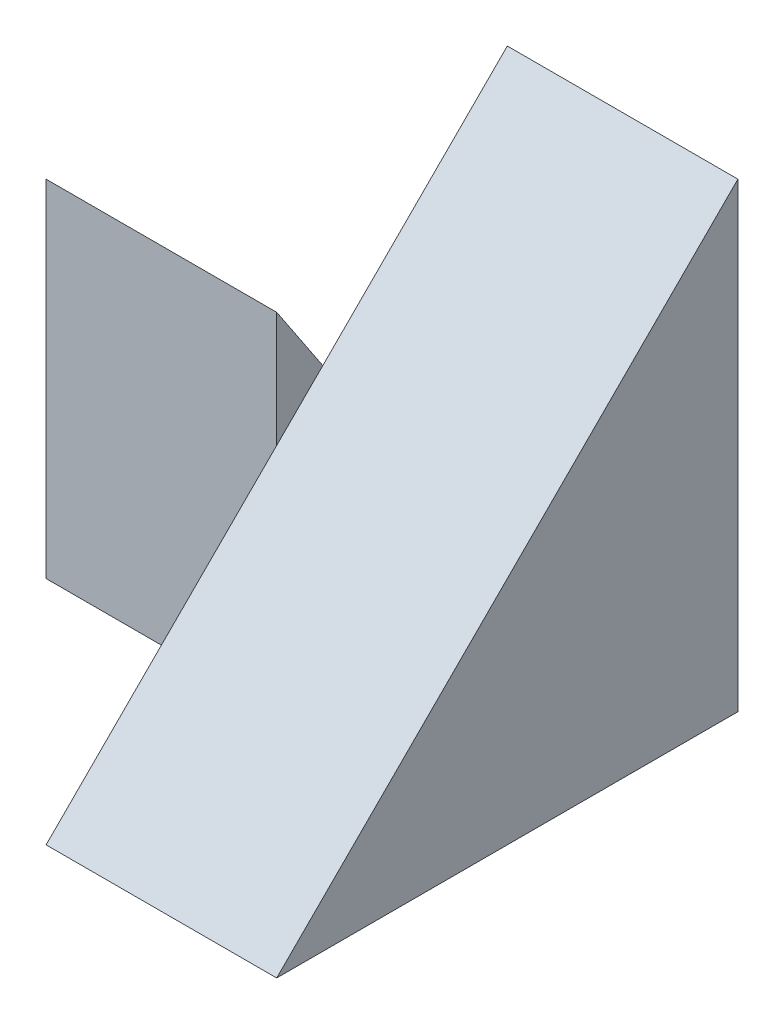
from build123d import *

# Parameters (mm, degrees)
SKETCH1_W           = 4
SKETCH1_H           = 4
BOSS_EXTRUDE1_DEPTH = 2
SKETCH2_W           = 2
SKETCH2_H           = 3
BOSS_EXTRUDE2_DEPTH = 2
CUT_EXTRUDE1_DEPTH  = 2
CUT_EXTRUDE2_DEPTH  = 2


with BuildPart() as part:
    # Sketch1 → Boss-Extrude1 (new body)
    with BuildSketch(Plane(origin=(0, 0, 0), x_dir=(0, 0, -1), z_dir=(1, 0, 0))):
        with Locations((2, 2)):
            Rectangle(SKETCH1_W, SKETCH1_H)
    extrude(amount=BOSS_EXTRUDE1_DEPTH)

    # Sketch2 → Boss-Extrude2 (add)
    with BuildSketch(Plane.ZY):
        with Locations((-3, 1.5)):
            Rectangle(SKETCH2_W, SKETCH2_H)
    extrude(amount=BOSS_EXTRUDE2_DEPTH)

    # Sketch3 → Cut-Extrude1 (cut)
    with BuildSketch(Plane.ZY.offset(2)):
        Polygon((-2, 3), (-4, 0), (-4, 3), align=None)
    extrude(amount=-CUT_EXTRUDE1_DEPTH, mode=Mode.SUBTRACT)

    # Sketch4 → Cut-Extrude2 (cut)
    with BuildSketch(Plane(origin=(2, 0, 0), x_dir=(0, 0, -1), z_dir=(1, 0, 0))):
        Polygon((4, 4), (0, 0), (0, 4), align=None)
    extrude(amount=-CUT_EXTRUDE2_DEPTH, mode=Mode.SUBTRACT)


solid = part.part
